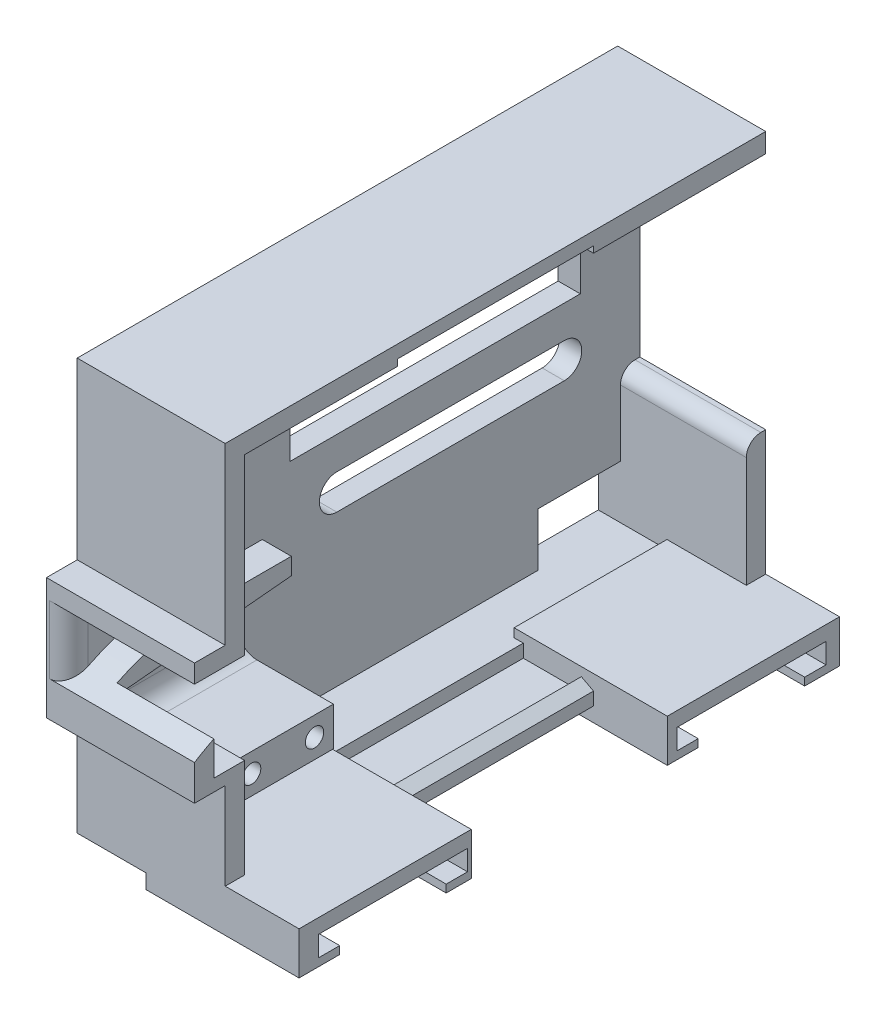
from build123d import *

# Parameters (mm, degrees)
MAIN_EXTRUDE_DEPTH            = 2.2875
WALLS_START                   = 2.2875
WALLS_DEPTH                   = 13
CORNER_SUPPORT_DEPTH          = 2
SKETCH2_R                     = 0.95
SKETCH2_W                     = 2.4
SKETCH2_H                     = 4
SKETCH2_W_2                   = 1
SWITCH_SPACER_DEPTH           = 9.9
ARM_SUPPORT_EXTRUDE_DEPTH     = 3
ARM_SUPPORT_CURVE_DEPTH       = 40.380356778
FILLET4_R                     = 2
FILLET3_R                     = 2
SKETCH2_5_R                   = 0.95
SWITCH_MOUNT_HOLES_DEPTH      = 40.380356889
SWITCH_MOUNT_HOLES_DEPTH_BACK = 40.380356889
SKETCH4_W                     = 8.5
SKETCH4_H                     = 5.5
WIRE_HOLE_DEPTH               = 40.380356889
SKETCH25_W                    = 6
SKETCH25_H                    = 1.35
FEMALE_SNAP_DEPTH             = 10.125
SKETCH5_W                     = 30
SKETCH5_H                     = 12.75
SERVO_HOLE_DEPTH              = 40.380356889
SKETCH30_W                    = 15.7875
SKETCH30_H                    = 0.9
SKETCH30_W_2                  = 17.7875
SKETCH30_H_2                  = 1.5
MAGNET_EXTRUDE_1_DEPTH        = 7.625
MAGNET_EXTRUDE_1_DEPTH_BACK   = 8.2
SKETCH29_R                    = 7.7
MAGNET_HOLE_DEPTH             = 2.1
SKETCH31_R                    = 5.5
MAGNET_THRU_HOLE_DEPTH        = 58.632218961


with BuildPart() as part:
    # Sketch1 → Main Extrude (new body)
    with BuildSketch(Plane(origin=(0, 0, 0), x_dir=(0, 0, -1), z_dir=(1, 0, 0))):
        Polygon((-30.5, -9.35), (-27.325, -9.35), (-27.325, -21.25), (28.5, -21.25), (28.5, 21.25), (-27.325, 21.25), (-27.325, 3.2), (-30.5, 3.2), align=None)
        with BuildLine():
            Line((20.7, -3.65), (-2.8, -3.65))
            ThreePointArc((-2.8, -3.65), (-4.6, -1.85), (-2.8, -0.05))
            Line((-2.8, -0.05), (20.7, -0.05))
            ThreePointArc((20.7, -0.05), (22.5, -1.85), (20.7, -3.65))
        make_face(mode=Mode.SUBTRACT)
    extrude(amount=MAIN_EXTRUDE_DEPTH)

    # Sketch1_3 → Walls (add)
    with BuildSketch(Plane(origin=(0, 0, 0), x_dir=(0, 0, -1), z_dir=(1, 0, 0)).offset(WALLS_START)):
        Polygon((-25.325, 19.25), (28.5, 19.25), (28.5, 21.25), (-27.325, 21.25), (-27.325, 3.2), (-30.5, 3.2), (-30.5, 1.3), (-25.325, 1.3), align=None)
        with BuildLine():
            Line((28.5, -5.425), (28, -5.425))
            ThreePointArc((28, -5.425), (26.939339828, -5.864339828), (26.5, -6.925))
            Line((26.5, -6.925), (26.5, -19.25))
            Line((26.5, -19.25), (-25.325, -19.25))
            Line((-25.325, -19.25), (-25.325, -8.1))
            Line((-25.325, -8.1), (-28.5, -8.1))
            Line((-28.5, -8.1), (-28.5, -4.45))
            Line((-28.5, -4.45), (-30.5, -4.45))
            Line((-30.5, -4.45), (-30.5, -9.35))
            Line((-30.5, -9.35), (-27.325, -9.35))
            Line((-27.325, -9.35), (-27.325, -21.25))
            Line((-27.325, -21.25), (28.5, -21.25))
            Line((28.5, -21.25), (28.5, -5.425))
        make_face()
    extrude(amount=WALLS_DEPTH)

    # Sketch22 → Corner Support (add)
    with BuildSketch(Plane(origin=(0, 0, -28.5), x_dir=(-1, 0, 0), z_dir=(0, 0, -1))):
        Polygon((-4.2875, 19.25), (-2.2875, 18.25), (-2.2875, 19.25), align=None)
    extrude(amount=-CORNER_SUPPORT_DEPTH)

    # Sketch2 → Switch Spacer (add)
    with BuildSketch(Plane(origin=(2.2875, 0, 0), x_dir=(0, 0, -1), z_dir=(1, 0, 0))):
        Polygon((-14.05, -10.75), (-17.05, -10.75), (-17.05, -14.75), (-14.05, -14.75), (-14.05, -12.75), align=None)
        with Locations((-15, -12.75)):
            Circle(SKETCH2_R, mode=Mode.SUBTRACT)
        with Locations((-15, -12.75)):
            Circle(SKETCH2_R)
        Polygon((-19.45, -10.75), (-22.45, -10.75), (-22.45, -12.75), (-22.45, -14.75), (-19.45, -14.75), align=None)
        with BuildLine():
            ThreePointArc((-20.55, -12.75), (-21.5, -13.7), (-22.45, -12.75))
            ThreePointArc((-22.45, -12.75), (-21.5, -11.8), (-20.55, -12.75))
        make_face(mode=Mode.SUBTRACT)
        with Locations((-21.5, -12.75)):
            Circle(SKETCH2_R)
        Polygon((-22.45, -12.75), (-22.45, -10.75), (-25.325, -10.75), (-25.325, -14.75), (-22.45, -14.75), align=None)
        with Locations((-18.25, -12.75)):
            Rectangle(SKETCH2_W, SKETCH2_H)
        with Locations((-13.55, -12.75)):
            Rectangle(SKETCH2_W_2, SKETCH2_H)
    extrude(amount=SWITCH_SPACER_DEPTH)

    # Sketch3 → Arm Support Extrude (add)
    with BuildSketch(Plane(origin=(2.2875, 0, 0), x_dir=(0, 0, -1), z_dir=(1, 0, 0))):
        with BuildLine():
            Line((-18.5, -2.25), (-10.5, -2.25))
            Line((-10.5, -2.25), (-10.5, -4))
            Line((-10.5, -4), (-28.5, -5.7))
            Line((-28.5, -5.7), (-30.5, -5.7))
            ThreePointArc((-30.5, -5.7), (-24.743046131, -3.129622151), (-18.5, -2.25))
        make_face()
    extrude(amount=ARM_SUPPORT_EXTRUDE_DEPTH)

    # Sketch7 → Arm Support Curve (cut, through all)
    with BuildSketch(Plane(origin=(2.2875, 0, 0), x_dir=(0, 0, -1), z_dir=(1, 0, 0))):
        with BuildLine():
            Line((-28.5, -4.583410824), (-28.5, -4.45))
            Line((-28.5, -4.45), (-30.5, -4.45))
            Line((-30.5, -4.45), (-30.5, -5.7))
            ThreePointArc((-30.5, -5.7), (-29.627655409, -5.180138898), (-28.73283292, -4.7))
            ThreePointArc((-28.73283292, -4.7), (-28.616584416, -4.641369997), (-28.5, -4.583410824))
        make_face()
    extrude(amount=ARM_SUPPORT_CURVE_DEPTH, mode=Mode.SUBTRACT)

    # Fillet4
    fillet4_edges = [part.edges().sort_by_distance(p)[0] for p in [
        (2.2875, -2.2, 30.5),
    ]]
    fillet(fillet4_edges, radius=FILLET4_R)

    # Fillet3
    fillet3_edges = [part.edges().sort_by_distance(p)[0] for p in [
        (2.2875, -14.75, 19.1875),
        (2.2875, -10.75, 19.1875),
    ]]
    fillet(fillet3_edges, radius=FILLET3_R)

    # Sketch2_5 → Switch Mount Holes (cut, two sides)
    with BuildSketch(Plane(origin=(2.2875, 0, 0), x_dir=(0, 0, -1), z_dir=(1, 0, 0))) as switch_mount_holes_sk:
        with Locations((-21.5, -12.75)):
            Circle(SKETCH2_5_R)
        with Locations((-15, -12.75)):
            Circle(SKETCH2_5_R)
    extrude(amount=SWITCH_MOUNT_HOLES_DEPTH, mode=Mode.SUBTRACT)
    extrude(switch_mount_holes_sk.sketch, amount=-SWITCH_MOUNT_HOLES_DEPTH_BACK, mode=Mode.SUBTRACT)

    # Sketch4 → Wire Hole (cut, through all)
    with BuildSketch(Plane(origin=(2.2875, 0, 0), x_dir=(0, 0, -1), z_dir=(1, 0, 0))):
        with Locations((22.25, -16.5)):
            Rectangle(SKETCH4_W, SKETCH4_H)
    extrude(amount=-WIRE_HOLE_DEPTH, mode=Mode.SUBTRACT)

    # Sketch25 → Female Snap (cut, symmetric)
    with BuildSketch(Plane(origin=(0, 0, -0.5875), x_dir=(-1, 0, 0), z_dir=(0, 0, -1))):
        with Locations((-11.0375, -19.925)):
            Rectangle(SKETCH25_W, SKETCH25_H)
        Polygon((-15.2875, -19.25), (-15.2875, -19.91463679), (-14.0375, -19.25), align=None)
        with Locations((-11.0375, 19.925)):
            Rectangle(SKETCH25_W, SKETCH25_H)
        Polygon((-15.2875, 19.91463679), (-15.2875, 19.25), (-14.0375, 19.25), align=None)
    extrude(amount=FEMALE_SNAP_DEPTH, both=True, mode=Mode.SUBTRACT)

    # Sketch5 → Servo Hole (cut, through all)
    with BuildSketch(Plane(origin=(2.2875, 0, 0), x_dir=(0, 0, -1), z_dir=(1, 0, 0))):
        with Locations((7.35, 9.675)):
            Rectangle(SKETCH5_W, SKETCH5_H)
        with BuildLine():
            Line((-8.75, 10.675), (-8.75, 8.675))
            ThreePointArc((-8.75, 8.675), (-10.3, 7.125), (-11.85, 8.675))
            Line((-11.85, 8.675), (-11.85, 10.675))
            ThreePointArc((-11.85, 10.675), (-10.3, 12.225), (-8.75, 10.675))
        make_face()
        with BuildLine():
            Line((26.55, 10.675), (26.55, 8.675))
            ThreePointArc((26.55, 8.675), (25, 7.125), (23.45, 8.675))
            Line((23.45, 8.675), (23.45, 10.675))
            ThreePointArc((23.45, 10.675), (25, 12.225), (26.55, 10.675))
        make_face()
    extrude(amount=-SERVO_HOLE_DEPTH, mode=Mode.SUBTRACT)

    # Sketch30 → Magnet Extrude 1 (add, two sides)
    with BuildSketch(Plane(origin=(15.2875, 0, 0), x_dir=(0, 0, -1), z_dir=(1, 0, 0))) as magnet_extrude_1_sk:
        Polygon((-27.325, -18.35), (-27.325, -21.25), (-9.5375, -21.25), (-9.5375, -19.91463679), (-9.5375, -19.25), (-25.325, -19.25), (-25.325, -18.35), align=None)
        with Locations((-17.43125, -18.8)):
            Rectangle(SKETCH30_W, SKETCH30_H)
        with Locations((19.60625, -22)):
            Rectangle(SKETCH30_W_2, SKETCH30_H_2)
        Polygon((10.7125, -19.91463679), (10.7125, -21.25), (28.5, -21.25), (28.5, -18.35), (26.5, -18.35), (26.5, -19.25), (10.7125, -19.25), align=None)
        with Locations((-18.43125, -22)):
            Rectangle(SKETCH30_W_2, SKETCH30_H_2)
        with Locations((18.60625, -18.8)):
            Rectangle(SKETCH30_W, SKETCH30_H)
    extrude(amount=MAGNET_EXTRUDE_1_DEPTH)
    extrude(magnet_extrude_1_sk.sketch, amount=-MAGNET_EXTRUDE_1_DEPTH_BACK)

    # Sketch29 → Magnet Hole (cut)
    with BuildSketch(Plane(origin=(0, -21.95, 0), x_dir=(1, 0, 0), z_dir=(0, 1, 0))):
        with Locations((15.2875, -17.625)):
            Circle(SKETCH29_R)
        with BuildLine():
            ThreePointArc((22.9125, -18.697089082), (20.338980677, -23.436414885), (15.2875, -25.325))
            Line((15.2875, -25.325), (22.9125, -25.325))
            Line((22.9125, -25.325), (22.9125, -18.697089082))
        make_face()
        with BuildLine():
            Line((22.9125, -9.925), (15.2875, -9.925))
            ThreePointArc((15.2875, -9.925), (20.338980677, -11.813585115), (22.9125, -16.552910918))
            Line((22.9125, -16.552910918), (22.9125, -9.925))
        make_face()
        with Locations((15.2875, 19.4)):
            Circle(SKETCH29_R)
        with BuildLine():
            ThreePointArc((22.9125, 18.327910918), (20.338980677, 13.588585115), (15.2875, 11.7))
            Line((15.2875, 11.7), (22.9125, 11.7))
            Line((22.9125, 11.7), (22.9125, 18.327910918))
        make_face()
        with BuildLine():
            Line((22.9125, 27.1), (15.2875, 27.1))
            ThreePointArc((15.2875, 27.1), (20.338980677, 25.211414885), (22.9125, 20.472089082))
            Line((22.9125, 20.472089082), (22.9125, 27.1))
        make_face()
        with BuildLine():
            ThreePointArc((22.9875, -17.625), (22.968727116, -17.087645368), (22.9125, -16.552910918))
            Line((22.9125, -16.552910918), (22.9125, -18.697089082))
            ThreePointArc((22.9125, -18.697089082), (22.968727116, -18.162354632), (22.9875, -17.625))
        make_face()
        with BuildLine():
            Line((22.9125, 20.472089082), (22.9125, 18.327910918))
            ThreePointArc((22.9125, 18.327910918), (22.968727116, 18.862645368), (22.9875, 19.4))
            ThreePointArc((22.9875, 19.4), (22.968727116, 19.937354632), (22.9125, 20.472089082))
        make_face()
    extrude(amount=MAGNET_HOLE_DEPTH, mode=Mode.SUBTRACT)

    # Sketch31 → Magnet Thru Hole (cut, through all)
    with BuildSketch(Plane.XZ.offset(21.95)):
        with Locations((15.2875, 17.625)):
            Circle(SKETCH31_R)
        with BuildLine():
            Line((22.9125, 23.125), (15.2875, 23.125))
            ThreePointArc((15.2875, 23.125), (19.176587297, 21.514087297), (20.7875, 17.625))
            ThreePointArc((20.7875, 17.625), (19.176587297, 13.735912703), (15.2875, 12.125))
            Line((15.2875, 12.125), (22.9125, 12.125))
            Line((22.9125, 12.125), (22.9125, 23.125))
        make_face()
        with Locations((15.2875, -19.4)):
            Circle(SKETCH31_R)
        with BuildLine():
            Line((22.9125, -13.9), (15.2875, -13.9))
            ThreePointArc((15.2875, -13.9), (19.176587297, -15.510912703), (20.7875, -19.4))
            ThreePointArc((20.7875, -19.4), (19.176587297, -23.289087297), (15.2875, -24.9))
            Line((15.2875, -24.9), (22.9125, -24.9))
            Line((22.9125, -24.9), (22.9125, -13.9))
        make_face()
    extrude(amount=MAGNET_THRU_HOLE_DEPTH, mode=Mode.SUBTRACT)


solid = part.part
